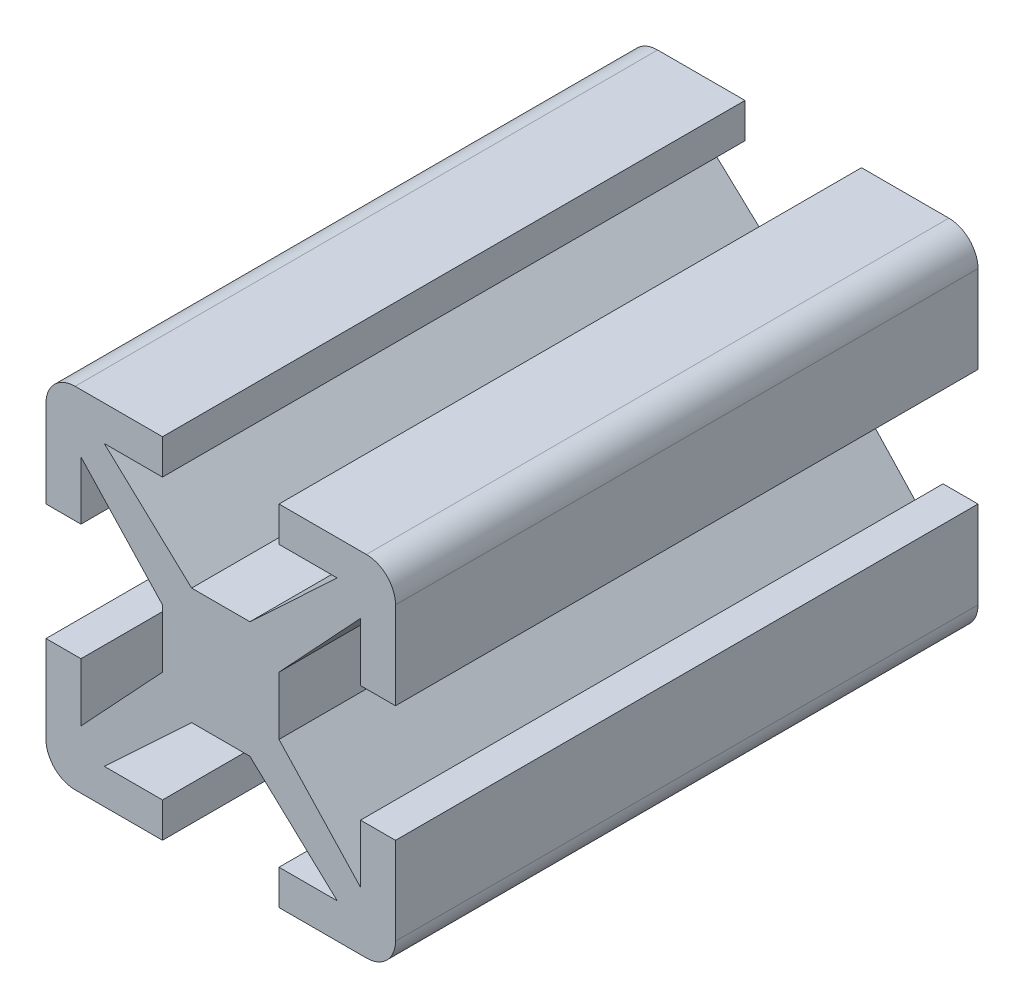
from build123d import *

# Parameters (mm, degrees)
EXTRUSION1_DEPTH             = 10
ENL_V_MAT_EXTRU_1_DEPTH      = 300
R_P_TITION_CIRCULAIRE1_COUNT = 4


with BuildPart() as part:
    # Esquisse1 → Extrusion1 (new, symmetric)
    with BuildSketch(Plane.XY):
        with BuildLine():
            Line((-6, 5), (-6, -5))
            ThreePointArc((-6, -5), (-5.707106781, -5.707106781), (-5, -6))
            Line((-5, -6), (5, -6))
            ThreePointArc((5, -6), (5.707106781, -5.707106781), (6, -5))
            Line((6, -5), (6, 5))
            ThreePointArc((6, 5), (5.707106781, 5.707106781), (5, 6))
            Line((5, 6), (-5, 6))
            ThreePointArc((-5, 6), (-5.707106781, 5.707106781), (-6, 5))
        make_face()
    extrude(amount=EXTRUSION1_DEPTH, both=True)

    # Esquisse3 → Enlèv. mat.-Extru.1 (cut)
    with BuildSketch(Plane.XY.offset(10)):
        Polygon((6, 2), (4.8, 2), (4.8, 4), (2, 1), (2, -1), (4.8, -4), (4.8, -2), (6, -2), align=None)
    enl_v_mat_extru_1 = extrude(amount=-ENL_V_MAT_EXTRU_1_DEPTH, mode=Mode.SUBTRACT)

    # Répétition circulaire1: Enlèv. mat.-Extru.1 ×4 about axis
    r_p_tition_circulaire1_axis = Axis((0, 0, -1), (0, 0, 1))
    for i in range(1, R_P_TITION_CIRCULAIRE1_COUNT):
        add(enl_v_mat_extru_1.rotate(r_p_tition_circulaire1_axis, i * 360 / R_P_TITION_CIRCULAIRE1_COUNT), mode=Mode.SUBTRACT)


solid = part.part
